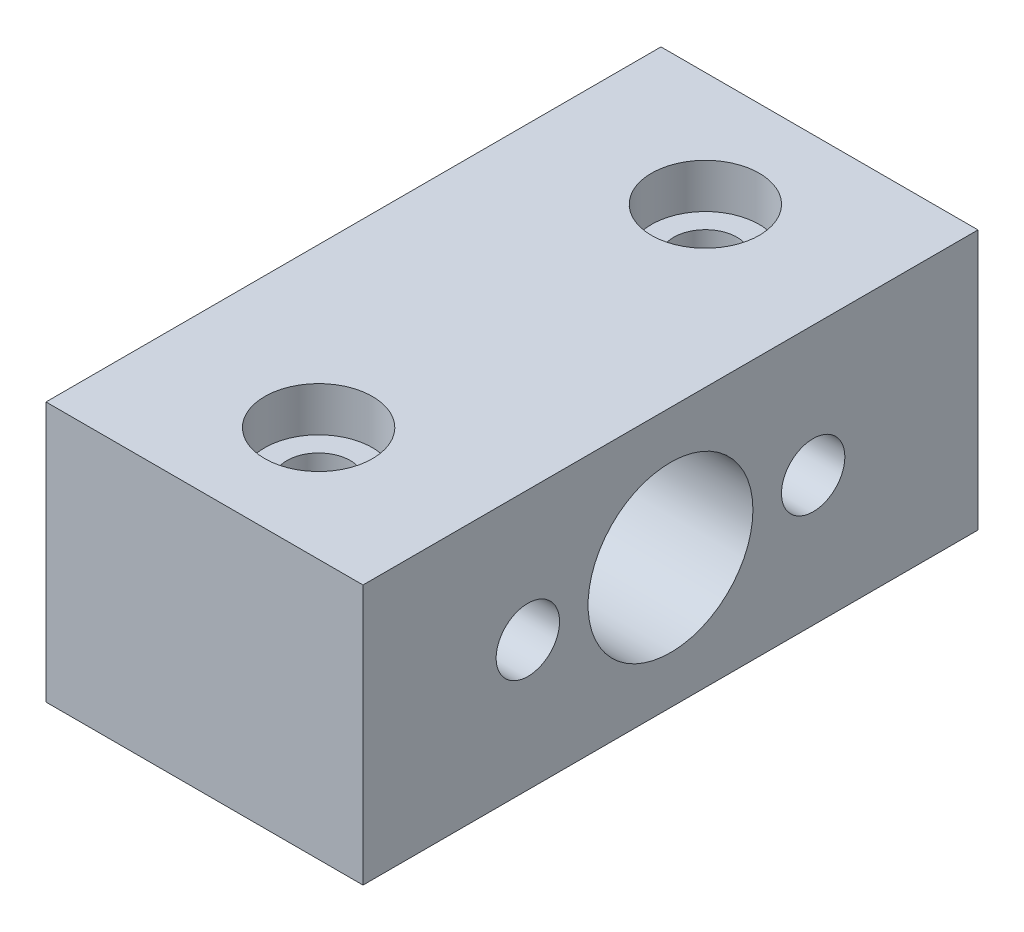
from build123d import *

# Parameters (mm, degrees)
SKETCH1_W           = 25
SKETCH1_H           = 20.5
BOSS_EXTRUDE1_DEPTH = 48.5
SKETCH2_R           = 4.25
CUT_EXTRUDE1_DEPTH  = 3.5
SKETCH3_R           = 2.5
CUT_EXTRUDE2_DEPTH  = 17
SKETCH4_R           = 6.5
CUT_EXTRUDE3_DEPTH  = 25
SKETCH5_R           = 2.5
CUT_EXTRUDE4_DEPTH  = 10


with BuildPart() as part:
    # Sketch1 → Boss-Extrude1 (new body)
    with BuildSketch(Plane.XY):
        with Locations((11.55511811, 8.921259843)):
            Rectangle(SKETCH1_W, SKETCH1_H)
    extrude(amount=BOSS_EXTRUDE1_DEPTH)

    # Sketch2 → Cut-Extrude1 (cut)
    with BuildSketch(Plane(origin=(0, 19.171259843, 0), x_dir=(1, 0, 0), z_dir=(0, 1, 0))):
        with Locations((11.55511811, -39.5)):
            Circle(SKETCH2_R)
        with Locations((11.55511811, -9)):
            Circle(SKETCH2_R)
    extrude(amount=-CUT_EXTRUDE1_DEPTH, mode=Mode.SUBTRACT)

    # Sketch3 → Cut-Extrude2 (cut)
    with BuildSketch(Plane(origin=(0, 15.671259843, 0), x_dir=(1, 0, 0), z_dir=(0, 1, 0))):
        with Locations((11.55511811, -39.5)):
            Circle(SKETCH3_R)
        with Locations((11.55511811, -9)):
            Circle(SKETCH3_R)
    extrude(amount=-CUT_EXTRUDE2_DEPTH, mode=Mode.SUBTRACT)

    # Sketch4 → Cut-Extrude3 (cut)
    with BuildSketch(Plane(origin=(24.05511811, 0, 0), x_dir=(0, 0, -1), z_dir=(1, 0, 0))):
        with Locations((-24.25, 8.921259843)):
            Circle(SKETCH4_R)
    extrude(amount=-CUT_EXTRUDE3_DEPTH, mode=Mode.SUBTRACT)

    # Sketch5 → Cut-Extrude4 (cut)
    with BuildSketch(Plane(origin=(24.05511811, 0, 0), x_dir=(0, 0, -1), z_dir=(1, 0, 0))):
        with Locations((-13, 8.921259843)):
            Circle(SKETCH5_R)
        with Locations((-35.5, 8.921259843)):
            Circle(SKETCH5_R)
    extrude(amount=-CUT_EXTRUDE4_DEPTH, mode=Mode.SUBTRACT)


solid = part.part
